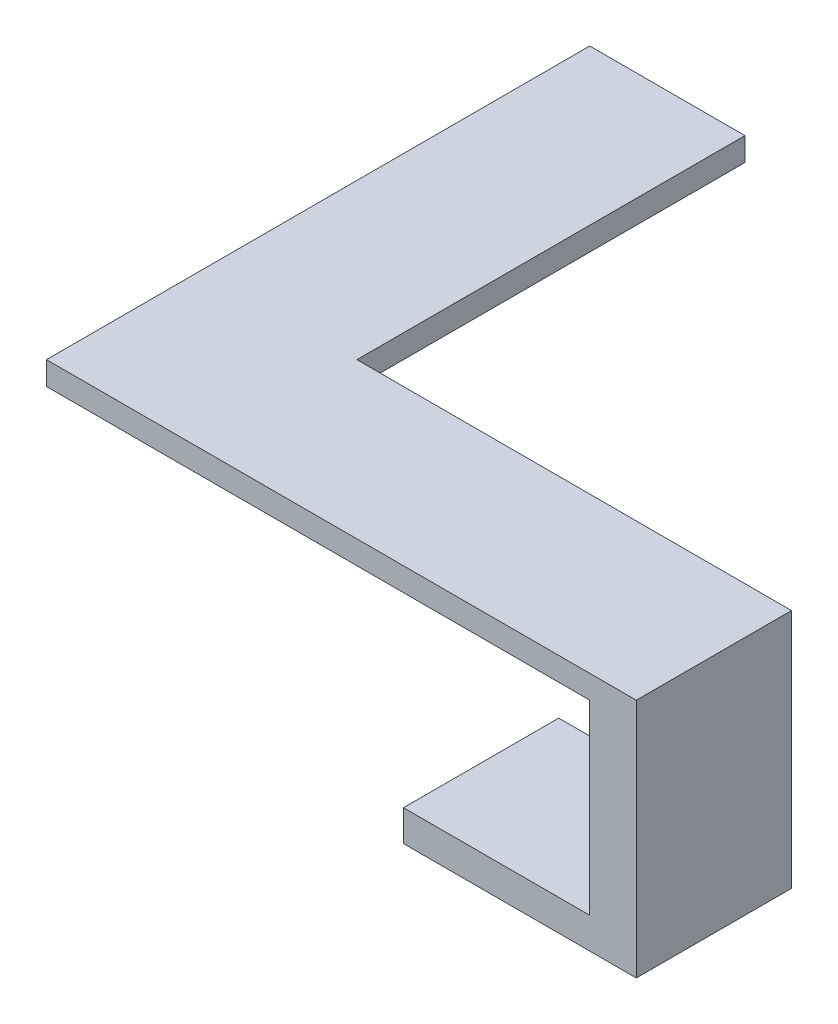
from build123d import *

# Parameters (mm, degrees)
BOSS_EXTRUDE1_DEPTH = 1.5
SKETCH2_W           = 3
SKETCH2_H           = 10
BOSS_EXTRUDE2_DEPTH = 14
SKETCH3_W           = 10
SKETCH3_H           = 2
BOSS_EXTRUDE3_DEPTH = 12


with BuildPart() as part:
    # Sketch1 → Boss-Extrude1 (new body)
    with BuildSketch(Plane(origin=(0, 0, 0), x_dir=(1, 0, 0), z_dir=(0, 1, 0))):
        Polygon((-10.528994658, 3.760355235), (-10.528994658, 28.760355235), (-20.528994658, 28.760355235), (-20.528994658, -6.239644765), (17.471005342, -6.239644765), (17.471005342, 3.760355235), align=None)
    extrude(amount=BOSS_EXTRUDE1_DEPTH)

    # Sketch2 → Boss-Extrude2 (add)
    with BuildSketch(Plane.XZ):
        with Locations((15.971005342, 1.239644765)):
            Rectangle(SKETCH2_W, SKETCH2_H)
    extrude(amount=BOSS_EXTRUDE2_DEPTH)

    # Sketch3 → Boss-Extrude3 (add)
    with BuildSketch(Plane.ZY.offset(-14.471005342)):
        with Locations((1.239644765, -13)):
            Rectangle(SKETCH3_W, SKETCH3_H)
    extrude(amount=BOSS_EXTRUDE3_DEPTH)


solid = part.part
